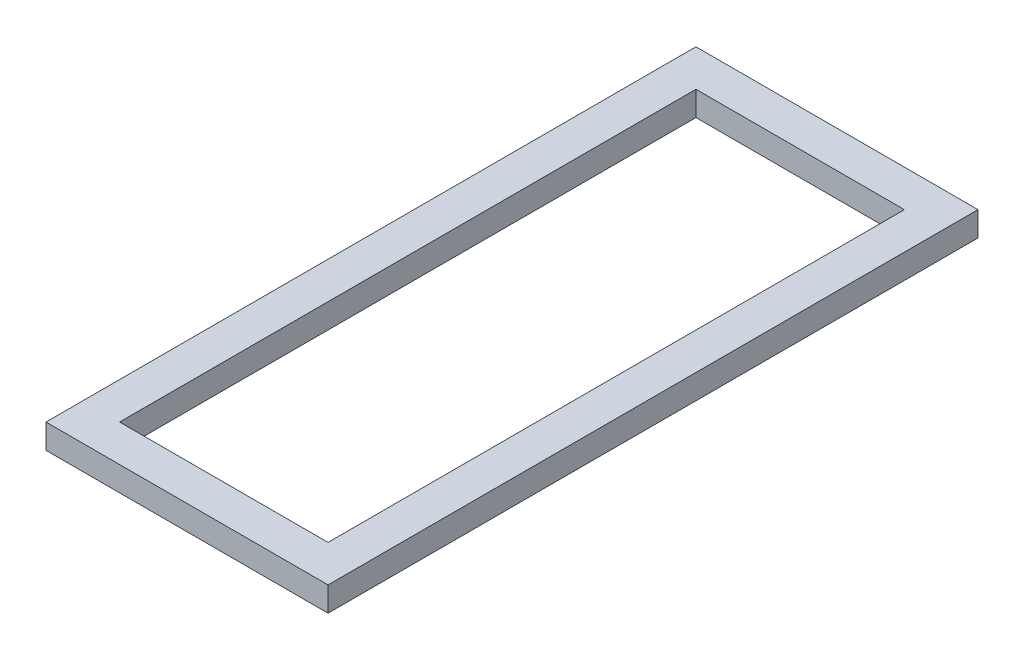
from build123d import *

# Parameters (mm, degrees)
SKETCH1_W           = 230
SKETCH1_H           = 530
SKETCH1_W_2         = 170
SKETCH1_H_2         = 470
EXTRUDE_THIN1_DEPTH = 20


with BuildPart() as part:
    # Sketch1 → Extrude-Thin1 (new body)
    with BuildSketch(Plane(origin=(0, 0, 0), x_dir=(1, 0, 0), z_dir=(0, 1, 0))):
        with Locations((5.936073059, 113.926940639)):
            Rectangle(SKETCH1_W, SKETCH1_H)
        with Locations((5.936073059, 113.926940639)):
            Rectangle(SKETCH1_W_2, SKETCH1_H_2, mode=Mode.SUBTRACT)
    extrude(amount=EXTRUDE_THIN1_DEPTH)


solid = part.part
